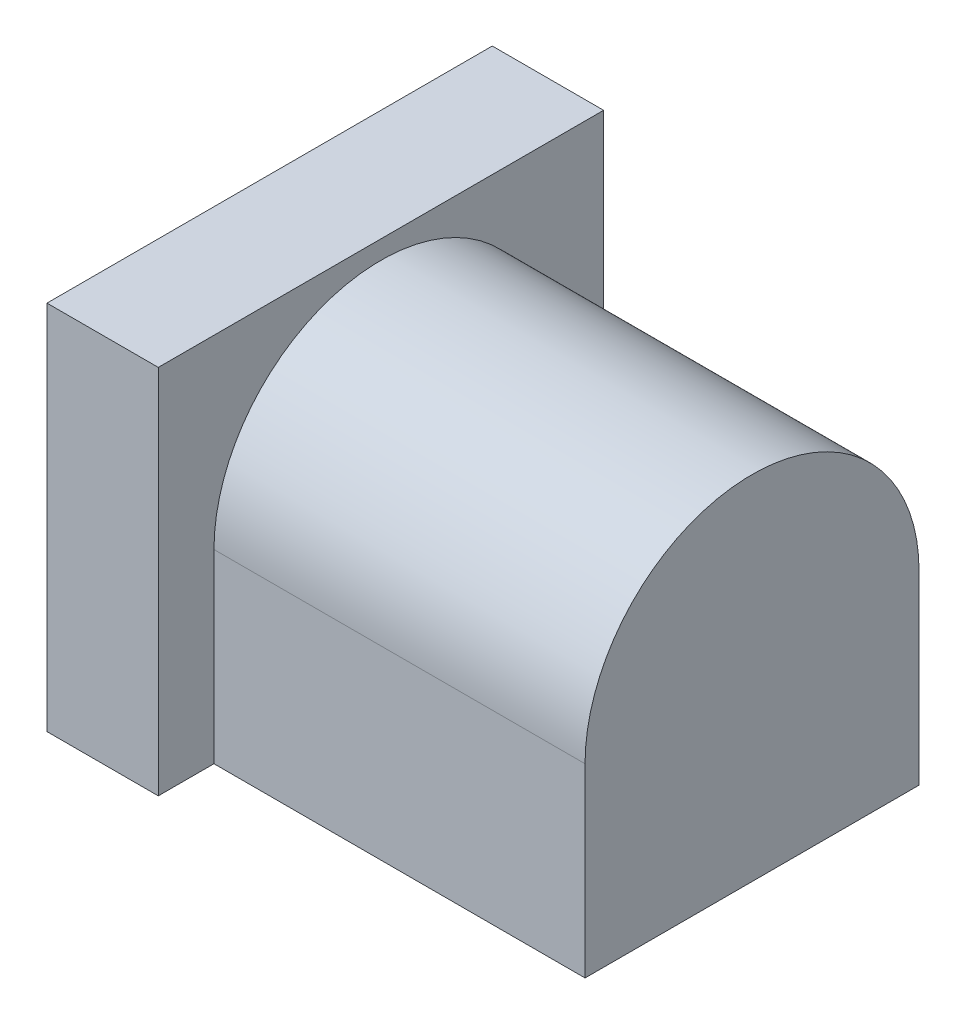
from build123d import *

# Parameters (mm, degrees)
BOSS_EXTRUDE1_DEPTH = 10
SKETCH2_W           = 12
SKETCH2_H           = 10
BOSS_EXTRUDE2_DEPTH = 3
SKETCH3_R           = 3
CUT_EXTRUDE1_DEPTH  = 12
SKETCH4_R           = 0.5
BOSS_EXTRUDE3_DEPTH = 10
FILLET6_R           = 0.5


with BuildPart() as part:
    # Sketch1 → Boss-Extrude1 (new body)
    with BuildSketch(Plane(origin=(0, 0, 0), x_dir=(0, 0, -1), z_dir=(1, 0, 0))):
        with BuildLine():
            Line((-4.5, -43.179278244), (4.5, -43.179278244))
            Line((4.5, -43.179278244), (4.5, -38.179278244))
            ThreePointArc((4.5, -38.179278244), (0, -33.679278244), (-4.5, -38.179278244))
            Line((-4.5, -38.179278244), (-4.5, -43.179278244))
        make_face()
    extrude(amount=BOSS_EXTRUDE1_DEPTH)

    # Sketch2 → Boss-Extrude2 (add)
    with BuildSketch(Plane.ZY):
        with Locations((0, -38.179278244)):
            Rectangle(SKETCH2_W, SKETCH2_H)
    extrude(amount=BOSS_EXTRUDE2_DEPTH)

    # Sketch3 → Cut-Extrude1 (cut)
    with BuildSketch(Plane.ZY.offset(3)):
        with Locations((0, -38.179278244)):
            Circle(SKETCH3_R)
    extrude(amount=-CUT_EXTRUDE1_DEPTH, mode=Mode.SUBTRACT)

    # Sketch4 → Boss-Extrude3 (add)
    with BuildSketch(Plane.ZY.offset(-9)):
        with Locations((0, -38.179278244)):
            Circle(SKETCH4_R)
    extrude(amount=BOSS_EXTRUDE3_DEPTH)

    # Fillet6
    fillet6_edges = [part.edges().sort_by_distance(p)[0] for p in [
        (-1, -38.179278244, -0.5),
    ]]
    fillet(fillet6_edges, radius=FILLET6_R)


solid = part.part
